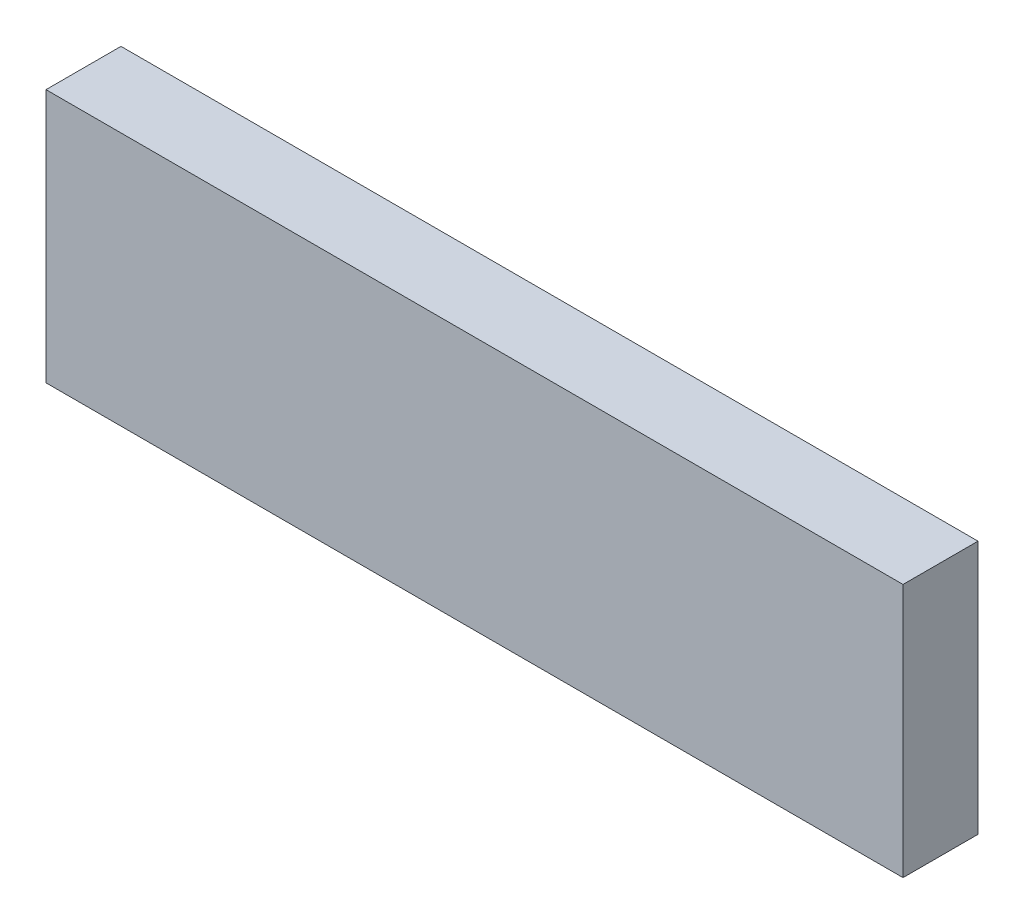
from build123d import *

# Parameters (mm, degrees)
SKETCH1_W           = 34.29
SKETCH1_H           = 10.16
BOSS_EXTRUDE1_DEPTH = 3


with BuildPart() as part:
    # Sketch1 → Boss-Extrude1 (new body)
    with BuildSketch(Plane.XY):
        with Locations((-17.145, 5.08)):
            Rectangle(SKETCH1_W, SKETCH1_H)
    extrude(amount=BOSS_EXTRUDE1_DEPTH)


solid = part.part
